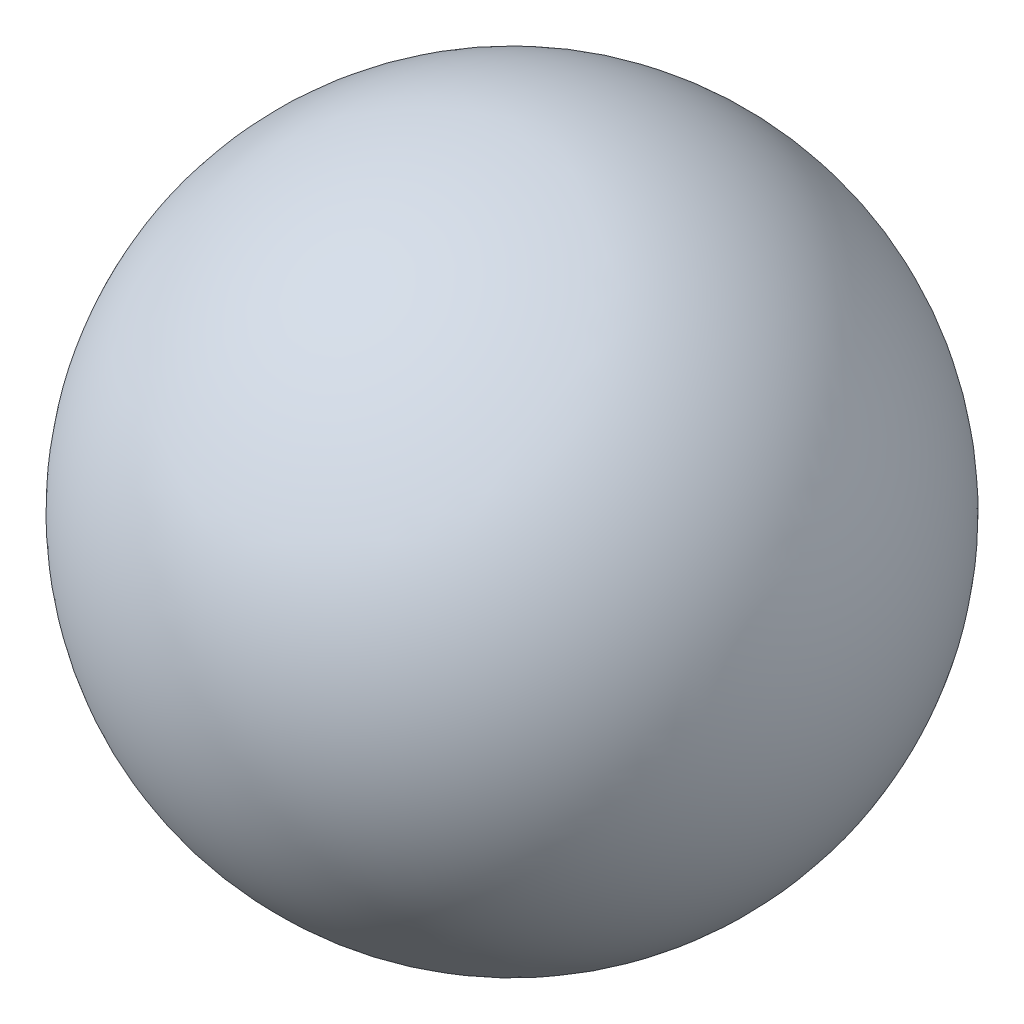
from build123d import *


with BuildPart() as part:
    # Esquisse1 → Révolution1 (revolve)
    with BuildSketch(Plane(origin=(0, 0, 0), x_dir=(1, 0, 0), z_dir=(0, 1, 0))):
        with BuildLine():
            Line((-250, 0), (250, 0))
            ThreePointArc((250, 0), (0, 250), (-250, 0))
        make_face()
    revolve(axis=Axis((-250, 0, 0), (1, 0, 0)))


solid = part.part
